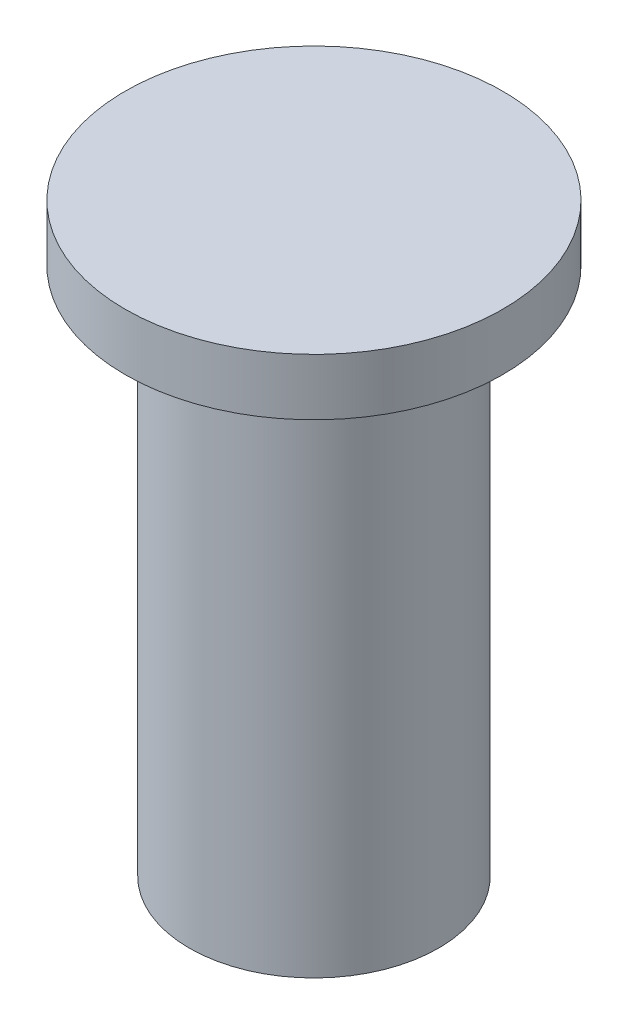
from build123d import *

# Parameters (mm, degrees)
SKETCH1_R           = 3.3
BOSS_EXTRUDE1_DEPTH = 14
SKETCH2_R           = 5
BOSS_EXTRUDE2_DEPTH = 1.5


with BuildPart() as part:
    # Sketch1 → Boss-Extrude1 (new body)
    with BuildSketch(Plane(origin=(0, 0, 0), x_dir=(1, 0, 0), z_dir=(0, 1, 0))):
        Circle(SKETCH1_R)
    extrude(amount=BOSS_EXTRUDE1_DEPTH)

    # Sketch2 → Boss-Extrude2 (add)
    with BuildSketch(Plane(origin=(0, 14, 0), x_dir=(1, 0, 0), z_dir=(0, 1, 0))):
        Circle(SKETCH2_R)
    extrude(amount=BOSS_EXTRUDE2_DEPTH)


solid = part.part
